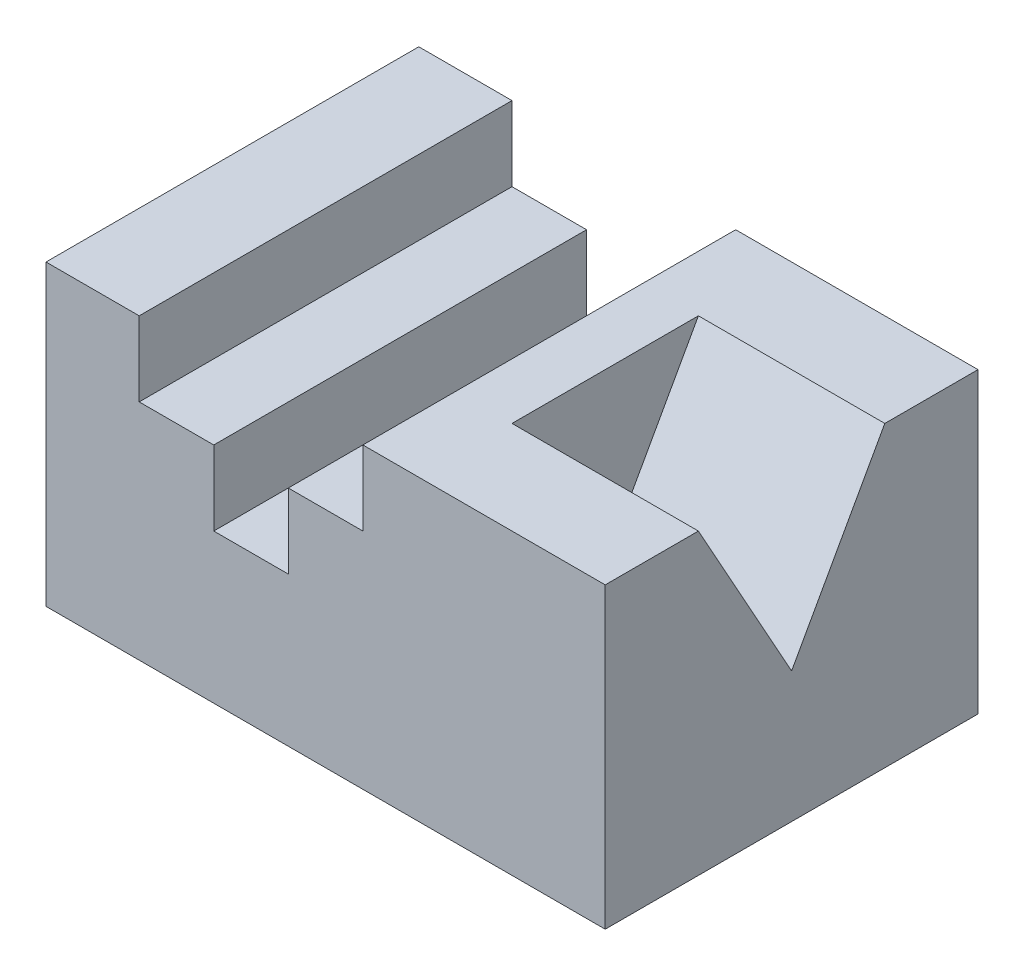
from build123d import *

# Parameters (mm, degrees)
SKETCH1_W               = 150
SKETCH1_H               = 80
BOSS_EXTRUDE1_DEPTH     = 100
SKETCH2_W               = 60
SKETCH2_H               = 20
CUT_EXTRUDE1_DEPTH      = 100
SKETCH3_W               = 20
SKETCH3_H               = 20
CUT_EXTRUDE2_DEPTH      = 100
CUT_EXTRUDE3_DEPTH      = 1
CUT_EXTRUDE3_DEPTH_BACK = 50


with BuildPart() as part:
    # Sketch1 → Boss-Extrude1 (new body)
    with BuildSketch(Plane.XY):
        with Locations((3.379828326, -4.983905579)):
            Rectangle(SKETCH1_W, SKETCH1_H)
    extrude(amount=-BOSS_EXTRUDE1_DEPTH)

    # Sketch2 → Cut-Extrude1 (cut)
    with BuildSketch(Plane.XY):
        with Locations((-16.620171674, 25.016094421)):
            Rectangle(SKETCH2_W, SKETCH2_H)
    extrude(amount=-CUT_EXTRUDE1_DEPTH, mode=Mode.SUBTRACT)

    # Sketch3 → Cut-Extrude2 (cut)
    with BuildSketch(Plane.XY):
        with Locations((-16.620171674, 5.016094421)):
            Rectangle(SKETCH3_W, SKETCH3_H)
    extrude(amount=-CUT_EXTRUDE2_DEPTH, mode=Mode.SUBTRACT)

    # Sketch4 → Cut-Extrude3 (cut, two sides)
    with BuildSketch(Plane(origin=(78.379828326, 0, 0), x_dir=(0, 0, -1), z_dir=(1, 0, 0))) as cut_extrude3_sk:
        Polygon((-86.366239295, 235.475325151), (25, 35.016094421), (50, -9.983905579), (75, 35.016094421), (186.366239295, 235.475325151), (186.366239295, 694.109569141), (-86.366239295, 694.109569141), align=None)
    extrude(amount=CUT_EXTRUDE3_DEPTH, mode=Mode.SUBTRACT)
    extrude(cut_extrude3_sk.sketch, amount=-CUT_EXTRUDE3_DEPTH_BACK, mode=Mode.SUBTRACT)


solid = part.part
